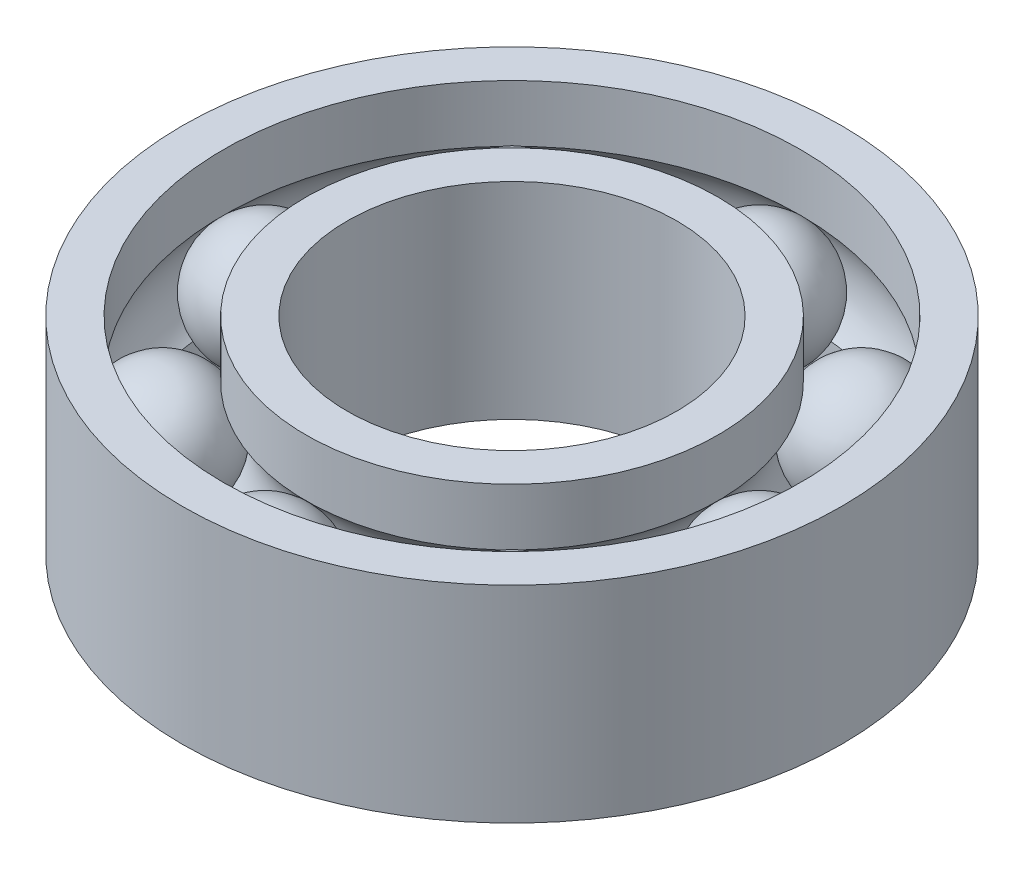
from build123d import *

# Parameters (mm, degrees)
CIRPATTERN2_COUNT = 8


with BuildPart() as part:
    # Sketch4 → Revolve4 (revolve)
    with BuildSketch(Plane.XY):
        with BuildLine():
            Line((-9, 2.25), (-9, -2.25))
            ThreePointArc((-9, -2.25), (-11.25, 0), (-9, 2.25))
        make_face()
    revolve(axis=Axis((-9, 2.25, 0), (0, -1, 0)))


with BuildPart() as body_2:
    # Sketch1 → Revolve5 (revolve)
    with BuildSketch(Plane.XY):
        with BuildLine():
            Line((-7.5, 3.75), (-6, 3.75))
            Line((-6, 3.75), (-6, -3.75))
            Line((-6, -3.75), (-7.5, -3.75))
            Line((-7.5, -3.75), (-7.5, -1.677050983))
            ThreePointArc((-7.5, -1.677050983), (-6.75, 0), (-7.5, 1.677050983))
            Line((-7.5, 1.677050983), (-7.5, 3.75))
        make_face()
        with BuildLine():
            Line((-12, 3.75), (-10.5, 3.75))
            Line((-10.5, 3.75), (-10.5, 1.677050983))
            ThreePointArc((-10.5, 1.677050983), (-11.25, 0), (-10.5, -1.677050983))
            Line((-10.5, -1.677050983), (-10.5, -3.75))
            Line((-10.5, -3.75), (-12, -3.75))
            Line((-12, -3.75), (-12, 3.75))
        make_face()
    revolve(axis=Axis((0, -4.125, 0), (0, 1, 0)))


with BuildPart() as cirpattern2_1:
    # CirPattern2: pattern copy
    add(part.part.rotate(Axis((0, 0, 0), (0, 1, 0)), 1 * 360 / CIRPATTERN2_COUNT))


with BuildPart() as cirpattern2_2:
    # CirPattern2: pattern copy
    add(part.part.rotate(Axis((0, 0, 0), (0, 1, 0)), 2 * 360 / CIRPATTERN2_COUNT))


with BuildPart() as cirpattern2_3:
    # CirPattern2: pattern copy
    add(part.part.rotate(Axis((0, 0, 0), (0, 1, 0)), 3 * 360 / CIRPATTERN2_COUNT))


with BuildPart() as cirpattern2_4:
    # CirPattern2: pattern copy
    add(part.part.rotate(Axis((0, 0, 0), (0, 1, 0)), 4 * 360 / CIRPATTERN2_COUNT))


with BuildPart() as cirpattern2_5:
    # CirPattern2: pattern copy
    add(part.part.rotate(Axis((0, 0, 0), (0, 1, 0)), 5 * 360 / CIRPATTERN2_COUNT))


with BuildPart() as cirpattern2_6:
    # CirPattern2: pattern copy
    add(part.part.rotate(Axis((0, 0, 0), (0, 1, 0)), 6 * 360 / CIRPATTERN2_COUNT))


with BuildPart() as cirpattern2_7:
    # CirPattern2: pattern copy
    add(part.part.rotate(Axis((0, 0, 0), (0, 1, 0)), 7 * 360 / CIRPATTERN2_COUNT))


solid = Compound([part.part, body_2.part, cirpattern2_1.part, cirpattern2_2.part, cirpattern2_3.part, cirpattern2_4.part, cirpattern2_5.part, cirpattern2_6.part, cirpattern2_7.part])
